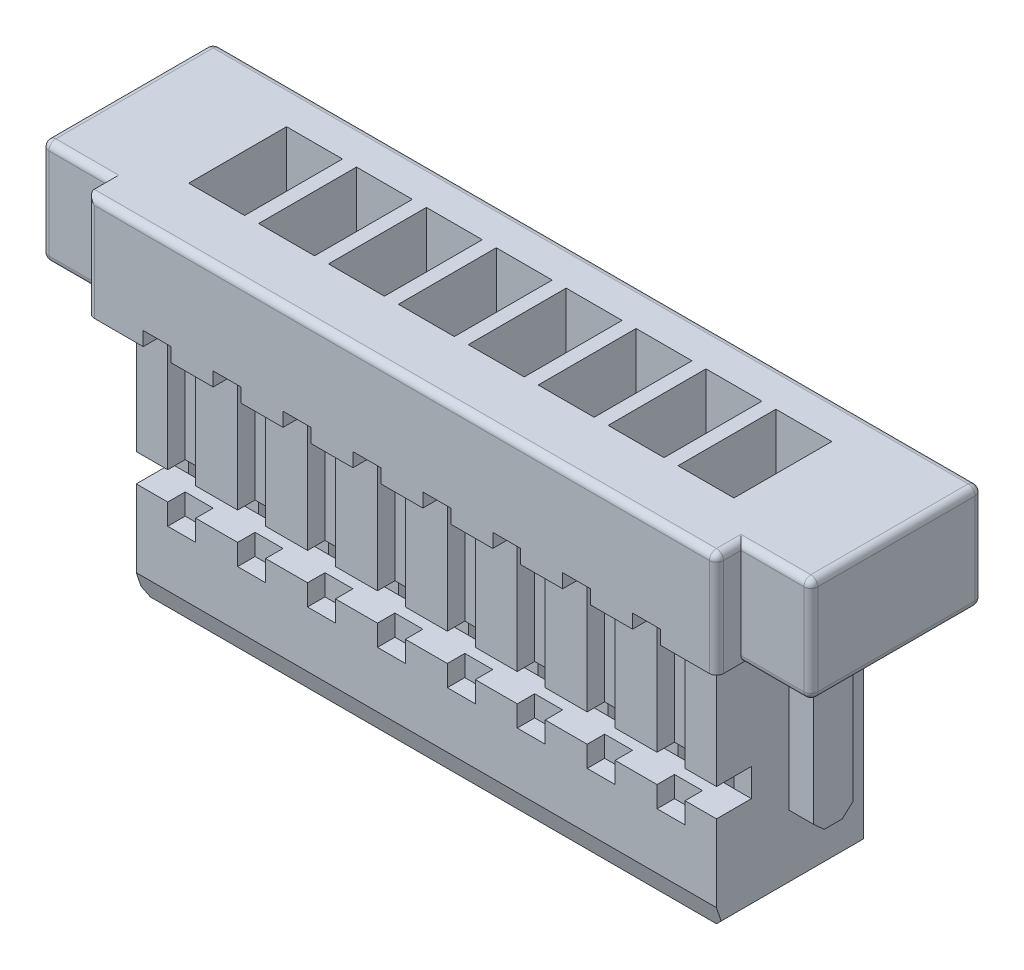
from build123d import *

# Parameters (mm, degrees)
EXTRUDE1_DEPTH      = 2.8
SKETCH2_W           = 0.35
SKETCH2_H           = 3.5
EXTRUDE2_DEPTH      = 6.5
EXTRUDE2_DEPTH_BACK = 6.5
SKETCH3_W           = 0.35
SKETCH3_H           = 1.5
EXTRUDE3_DEPTH      = 1
EXTRUDE4_DEPTH      = 0.35
SKETCH5_W           = 0.5
SKETCH5_H           = 0.4
EXTRUDE5_DEPTH      = 10.65
SKETCH6_W           = 0.8
SKETCH6_H           = 1.4
EXTRUDE6_DEPTH      = 4.5
LPATTERN1_COUNT     = 8
LPATTERN1_PITCH     = 1
SKETCH7_W           = 0.4
SKETCH7_H           = 2.6
EXTRUDE7_DEPTH      = 0.6
LPATTERN2_COUNT     = 8
LPATTERN2_PITCH     = 1
SKETCH9_W           = 0.5
SKETCH9_H           = 0.5
EXTRUDE9_DEPTH      = 0.35
LPATTERN3_COUNT     = 8
LPATTERN3_PITCH     = 1
SKETCH10_W          = 0.35
SKETCH10_H          = 0.75
EXTRUDE10_DEPTH     = 6
LPATTERN4_COUNT     = 8
LPATTERN4_PITCH     = 1
FILLET1_R           = 0.1
CHAMFER1_SIZE       = 0.1
CHAMFER1_SIZE2      = 0.3
CHAMFER2_SIZE       = 0.1


with BuildPart() as part:
    # Sketch1 → Extrude1 (new body)
    with BuildSketch(Plane.XY):
        Polygon((-5.5, 1), (-4.5, 1), (-4.5, -2.5), (4.5, -2.5), (4.5, 1), (5.5, 1), (5.5, 2.5), (-5.5, 2.5), align=None)
    extrude(amount=EXTRUDE1_DEPTH)

    # Sketch2 → Extrude2 (cut, two sides)
    with BuildSketch(Plane(origin=(0, 0, 0), x_dir=(0, 0, -1), z_dir=(1, 0, 0))) as extrude2_sk:
        with Locations((-2.625, -0.75)):
            Rectangle(SKETCH2_W, SKETCH2_H)
        with Locations((-0.175, -0.75)):
            Rectangle(SKETCH2_W, SKETCH2_H)
    extrude(amount=EXTRUDE2_DEPTH, mode=Mode.SUBTRACT)
    extrude(extrude2_sk.sketch, amount=-EXTRUDE2_DEPTH_BACK, mode=Mode.SUBTRACT)

    # Sketch3 → Extrude3 (cut)
    with BuildSketch(Plane(origin=(5.5, 0, 0), x_dir=(0, 0, -1), z_dir=(1, 0, 0))):
        with Locations((-2.625, 1.75)):
            Rectangle(SKETCH3_W, SKETCH3_H)
    extrude3 = extrude(amount=-EXTRUDE3_DEPTH, mode=Mode.SUBTRACT)

    # Mirror1: Extrude3 across plane
    add(extrude3.mirror(Plane(origin=(0, 0, 0), x_dir=(0, 0, 1), z_dir=(1, 0, 0))), mode=Mode.SUBTRACT)

    # Sketch4 → Extrude4 (cut)
    with BuildSketch(Plane(origin=(4.5, 0, 0), x_dir=(0, 0, -1), z_dir=(1, 0, 0))):
        Polygon((-1.41, 1), (-1.41, -1.513059307), (-1.26, -1.65), (-1, -1.65), (-0.85, -1.513059307), (-0.85, 1), (-0.35, 1), (-0.35, -2.5), (-2.45, -2.5), (-2.45, 1), align=None)
    extrude4 = extrude(amount=-EXTRUDE4_DEPTH, mode=Mode.SUBTRACT)

    # Mirror2: Extrude4 across plane
    add(extrude4.mirror(Plane(origin=(0, 0, 0), x_dir=(0, 0, 1), z_dir=(1, 0, 0))), mode=Mode.SUBTRACT)

    # Sketch5 → Extrude5 (cut, through all)
    with BuildSketch(Plane(origin=(4.15, 0, 0), x_dir=(0, 0, -1), z_dir=(1, 0, 0))):
        with Locations((-2.2, -0.9)):
            Rectangle(SKETCH5_W, SKETCH5_H)
    extrude(amount=-EXTRUDE5_DEPTH, mode=Mode.SUBTRACT)

    # Sketch6 → Extrude6 (cut)
    with BuildSketch(Plane(origin=(0, 2.5, 0), x_dir=(1, 0, 0), z_dir=(0, 1, 0))):
        with Locations((-3.5, -1.25)):
            Rectangle(SKETCH6_W, SKETCH6_H)
    extrude6 = extrude(amount=-EXTRUDE6_DEPTH, mode=Mode.SUBTRACT)

    # LPattern1: Extrude6 ×8
    with Locations(*[(i * LPATTERN1_PITCH, 0, 0) for i in range(1, LPATTERN1_COUNT)]):
        add(extrude6, mode=Mode.SUBTRACT)

    # Sketch7 → Extrude7 (cut)
    with BuildSketch(Plane.XY.offset(2.8)):
        with Locations((-3.5, -0.1)):
            Rectangle(SKETCH7_W, SKETCH7_H)
    extrude7 = extrude(amount=-EXTRUDE7_DEPTH, mode=Mode.SUBTRACT)

    # LPattern2: Extrude7 ×8
    with Locations(*[(i * LPATTERN2_PITCH, 0, 0) for i in range(1, LPATTERN2_COUNT)]):
        add(extrude7, mode=Mode.SUBTRACT)

    # Sketch9 → Extrude9 (cut)
    with BuildSketch(Plane(origin=(0, 0, 0), x_dir=(-1, 0, 0), z_dir=(0, 0, -1))):
        with Locations((-3.5, 1.25)):
            Rectangle(SKETCH9_W, SKETCH9_H)
    extrude9 = extrude(amount=-EXTRUDE9_DEPTH, mode=Mode.SUBTRACT)

    # LPattern3: Extrude9 ×8
    with Locations(*[(-i * LPATTERN3_PITCH, 0, 0) for i in range(1, LPATTERN3_COUNT)]):
        add(extrude9, mode=Mode.SUBTRACT)

    # Sketch10 → Extrude10 (cut, through all)
    with BuildSketch(Plane.XZ.offset(2.5)):
        with Locations((-3.5, 1.025)):
            Rectangle(SKETCH10_W, SKETCH10_H)
    extrude10 = extrude(amount=-EXTRUDE10_DEPTH, mode=Mode.SUBTRACT)

    # LPattern4: Extrude10 ×8
    with Locations(*[(i * LPATTERN4_PITCH, 0, 0) for i in range(1, LPATTERN4_COUNT)]):
        add(extrude10, mode=Mode.SUBTRACT)

    # Fillet1
    fillet1_edges = [part.edges().sort_by_distance(p)[0] for p in [
        (0, 2.5, 0),
        (5.5, 1.75, 0),
        (4.625, 1, 0),
        (0, 2.5, 2.8),
        (5.5, 1, 1.225),
        (5.5, 2.5, 1.225),
        (5, 1, 2.45),
        (4.5, 1.75, 2.8),
        (4.5, 2.5, 2.625),
        (5, 2.5, 2.45),
        (5.5, 1.75, 2.45),
        (-4.625, 1, 0),
        (-5.5, 1, 1.225),
        (-5.5, 2.5, 1.225),
        (-5.5, 1.75, 2.45),
        (-5, 1, 2.45),
        (-5, 2.5, 2.45),
        (-4.5, 1.75, 2.8),
        (-5.5, 1.75, 0),
    ]]
    fillet(fillet1_edges, radius=FILLET1_R)

    # Chamfer1
    chamfer1_edges = [part.edges().sort_by_distance(p)[0] for p in [
        (0, -2.5, 2.45),
    ]]
    chamfer1_side = [part.faces().sort_by_distance(p)[0] for p in [
        (0, -2.5, 1.451369863),
    ]]
    chamfer(chamfer1_edges, length=CHAMFER1_SIZE, length2=CHAMFER1_SIZE2, reference=chamfer1_side[0])

    # Chamfer2
    chamfer2_edges = [part.edges().sort_by_distance(p)[0] for p in [
        (0, -2.5, 0.35),
        (4.15, -2.5, 1.35),
        (-4.15, -2.5, 1.35),
    ]]
    chamfer(chamfer2_edges, length=CHAMFER2_SIZE)


solid = part.part
